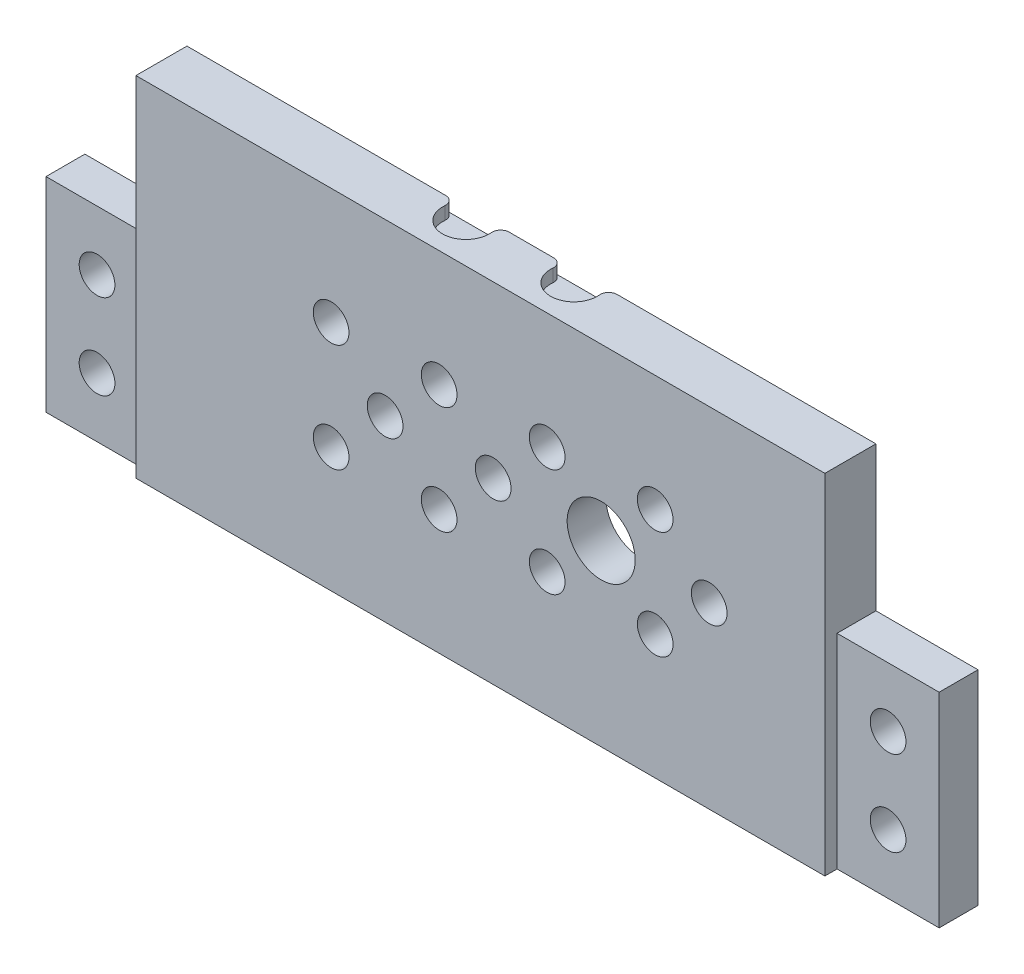
from build123d import *

# Parameters (mm, degrees)
SKETCH1_W           = 81
SKETCH1_H           = 41
BOSS_EXTRUDE1_DEPTH = 6
SKETCH5_W           = 75
SKETCH5_H           = 35
CUT_EXTRUDE1_DEPTH  = 1.43
SKETCH8_R           = 2.1
SKETCH8_R_2         = 4
CUT_EXTRUDE2_DEPTH  = 7
SKETCH9_R           = 2.75
CUT_EXTRUDE3_DEPTH  = 1.5
FILLET1_R           = 1
SKETCH10_W          = 4.57
SKETCH10_H          = 24
BOSS_EXTRUDE2_DEPTH = 12
SKETCH12_W          = 4.57
SKETCH12_H          = 24
BOSS_EXTRUDE3_DEPTH = 12
SKETCH13_R          = 2.1
CUT_EXTRUDE4_DEPTH  = 5.57


with BuildPart() as part:
    # Sketch1 → Boss-Extrude1 (new body)
    with BuildSketch(Plane.XY):
        Rectangle(SKETCH1_W, SKETCH1_H)
    extrude(amount=BOSS_EXTRUDE1_DEPTH)

    # Sketch5 → Cut-Extrude1 (cut)
    with BuildSketch(Plane(origin=(0, 0, 0), x_dir=(-1, 0, 0), z_dir=(0, 0, -1))):
        Rectangle(SKETCH5_W, SKETCH5_H)
    extrude(amount=-CUT_EXTRUDE1_DEPTH, mode=Mode.SUBTRACT)

    # Sketch8 → Cut-Extrude2 (cut, through all)
    with BuildSketch(Plane.XY.offset(6)):
        with Locations((26.9, 0.5)):
            Circle(SKETCH8_R)
        with Locations((20.55, 6.849637785)):
            Circle(SKETCH8_R)
        with Locations((7.85, 6.849637785)):
            Circle(SKETCH8_R)
        with Locations((7.85, -5.849637785)):
            Circle(SKETCH8_R)
        with Locations((20.55, -5.849637785)):
            Circle(SKETCH8_R)
        with Locations((1.5, 0.5)):
            Circle(SKETCH8_R)
        with Locations((-4.85, 6.849637785)):
            Circle(SKETCH8_R)
        with Locations((-4.85, -5.849637785)):
            Circle(SKETCH8_R)
        with Locations((-11.2, 0.5)):
            Circle(SKETCH8_R)
        with Locations((-17.55, 6.849637785)):
            Circle(SKETCH8_R)
        with Locations((-17.55, -5.849637785)):
            Circle(SKETCH8_R)
        with Locations((14.2, 0.5)):
            Circle(SKETCH8_R_2)
    extrude(amount=-CUT_EXTRUDE2_DEPTH, mode=Mode.SUBTRACT)

    # Sketch9 → Cut-Extrude3 (cut)
    with BuildSketch(Plane(origin=(0, 20.5, 0), x_dir=(1, 0, 0), z_dir=(0, 1, 0))):
        with Locations((6.35, -1.35)):
            Circle(SKETCH9_R)
        with Locations((-6.35, -1.35)):
            Circle(SKETCH9_R)
    extrude(amount=-CUT_EXTRUDE3_DEPTH, mode=Mode.SUBTRACT)

    # Fillet1
    fillet1_edges = [part.edges().sort_by_distance(p)[0] for p in [
        (-8.74582971, 19.75, 0),
        (-3.95417029, 19.75, 0),
        (3.95417029, 19.75, 0),
        (8.74582971, 19.75, 0),
    ]]
    fillet(fillet1_edges, radius=FILLET1_R)

    # Sketch10 → Boss-Extrude2 (add)
    with BuildSketch(Plane.ZY.offset(40.5)):
        with Locations((2.285, -8.5)):
            Rectangle(SKETCH10_W, SKETCH10_H)
    extrude(amount=BOSS_EXTRUDE2_DEPTH)

    # Sketch12 → Boss-Extrude3 (add)
    with BuildSketch(Plane(origin=(40.5, 0, 0), x_dir=(0, 0, -1), z_dir=(1, 0, 0))):
        with Locations((-2.285, -8.5)):
            Rectangle(SKETCH12_W, SKETCH12_H)
    extrude(amount=BOSS_EXTRUDE3_DEPTH)

    # Sketch13 → Cut-Extrude4 (cut, through all)
    with BuildSketch(Plane.XY.offset(4.57)):
        with Locations((-46.5, -3.5)):
            Circle(SKETCH13_R)
        with Locations((-46.5, -13.5)):
            Circle(SKETCH13_R)
        with Locations((46.5, -3.5)):
            Circle(SKETCH13_R)
        with Locations((46.5, -13.5)):
            Circle(SKETCH13_R)
    extrude(amount=-CUT_EXTRUDE4_DEPTH, mode=Mode.SUBTRACT)


solid = part.part
